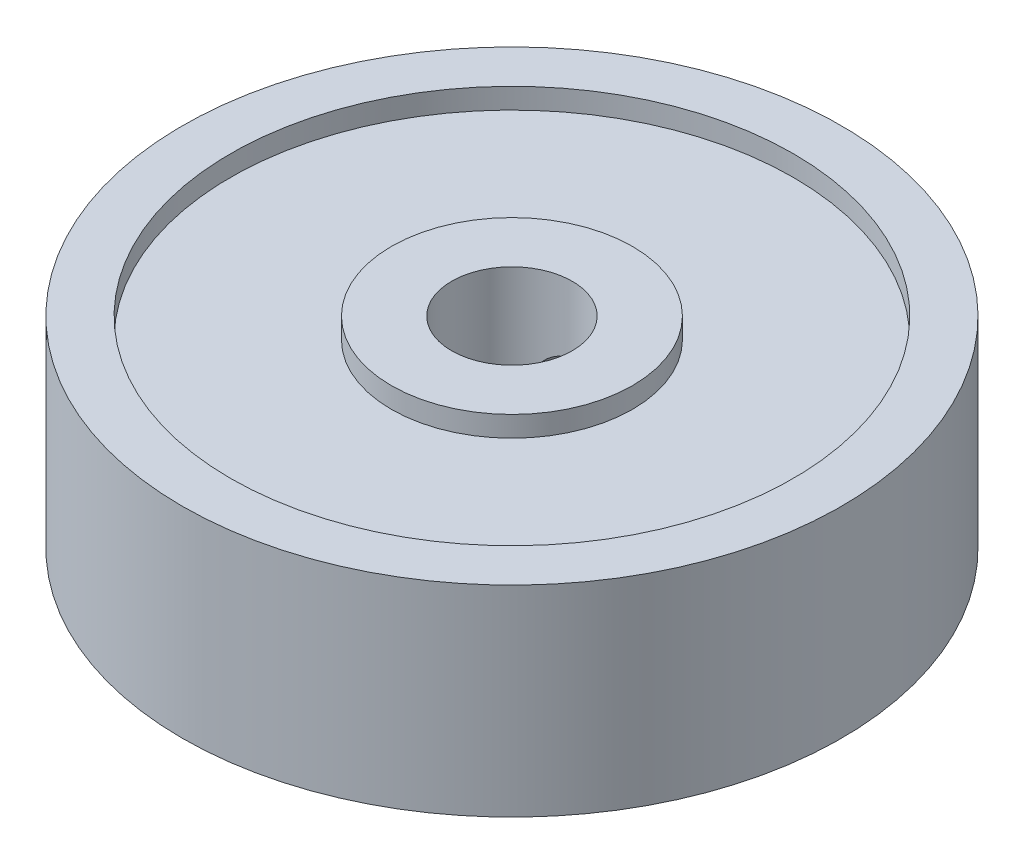
from build123d import *

# Parameters (mm, degrees)
SKETCH1_R           = 13.0175
SKETCH1_R_2         = 2.38125
BOSS_EXTRUDE1_DEPTH = 7.9375
SKETCH2_R           = 11.1125
SKETCH2_R_2         = 4.7625
CUT_EXTRUDE1_DEPTH  = 0.8128
SKETCH3_R           = 11.1125
SKETCH3_R_2         = 4.7625
CUT_EXTRUDE2_DEPTH  = 0.8128
SKETCH4_R           = 1.28905
CUT_EXTRUDE3_DEPTH  = 14.0175


with BuildPart() as part:
    # Sketch1 → Boss-Extrude1 (new body)
    with BuildSketch(Plane(origin=(0, 0, 0), x_dir=(1, 0, 0), z_dir=(0, 1, 0))):
        Circle(SKETCH1_R)
        Circle(SKETCH1_R_2, mode=Mode.SUBTRACT)
    extrude(amount=BOSS_EXTRUDE1_DEPTH)

    # Sketch2 → Cut-Extrude1 (cut)
    with BuildSketch(Plane(origin=(0, 7.9375, 0), x_dir=(1, 0, 0), z_dir=(0, 1, 0))):
        Circle(SKETCH2_R)
        Circle(SKETCH2_R_2, mode=Mode.SUBTRACT)
    extrude(amount=-CUT_EXTRUDE1_DEPTH, mode=Mode.SUBTRACT)

    # Sketch3 → Cut-Extrude2 (cut)
    with BuildSketch(Plane.XZ):
        Circle(SKETCH3_R)
        Circle(SKETCH3_R_2, mode=Mode.SUBTRACT)
    extrude(amount=-CUT_EXTRUDE2_DEPTH, mode=Mode.SUBTRACT)

    # Sketch4 → Cut-Extrude3 (cut, through all)
    with BuildSketch(Plane.XY):
        with Locations((0, 3.9624)):
            Circle(SKETCH4_R)
    extrude(amount=-CUT_EXTRUDE3_DEPTH, mode=Mode.SUBTRACT)


solid = part.part
